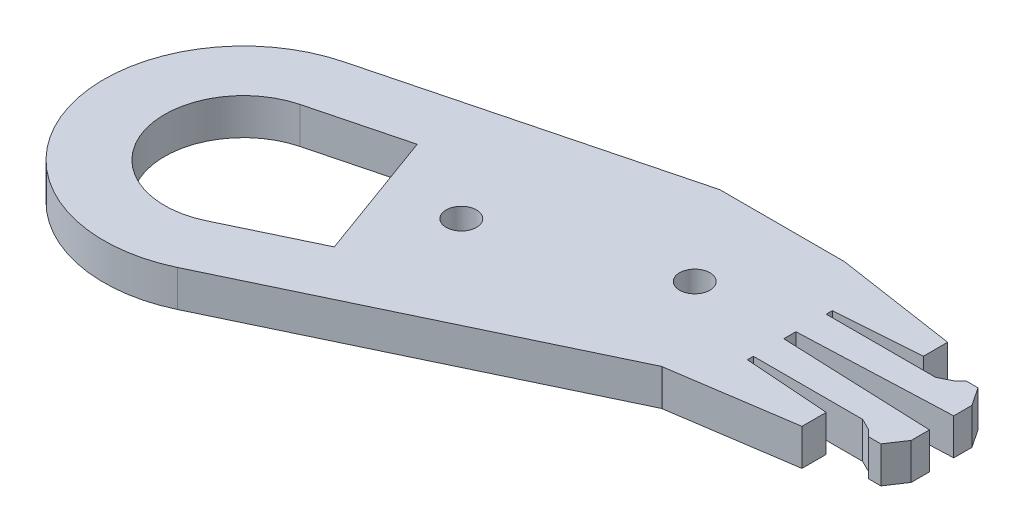
from build123d import *

# Parameters (mm, degrees)
SKETCH4_R           = 1.25
BOSS_EXTRUDE2_DEPTH = 3


with BuildPart() as part:
    # Sketch4 → Boss-Extrude2 (new body)
    with BuildSketch(Plane(origin=(0, 0, 0), x_dir=(1, 0, 0), z_dir=(0, 1, 0))):
        with BuildLine():
            Line((-2.879370047, 11.133697864), (21.737293787, 17.5))
            Line((21.737293787, 17.5), (32, 17.5))
            Line((32, 17.5), (42, 16))
            Line((42, 16), (42, 14))
            Line((42, 14), (35, 13.5))
            Line((35, 13.5), (35, 13))
            Line((35, 13), (44, 13))
            Line((44, 13), (45, 13.5))
            Line((45, 13.5), (45.5, 14))
            Line((45.5, 14), (46.5, 14))
            Line((46.5, 14), (47.5, 12.5))
            Line((47.5, 12.5), (47.5, 11))
            Line((47.5, 11), (35, 10.5))
            Line((35, 10.5), (35, 9.5))
            Line((35, 9.5), (47.5, 9))
            Line((47.5, 9), (47.5, 7.5))
            Line((47.5, 7.5), (46.5, 6))
            Line((46.5, 6), (45.5, 6))
            Line((45.5, 6), (45, 6.5))
            Line((45, 6.5), (44, 7))
            Line((44, 7), (35, 7))
            Line((35, 7), (35, 6.5))
            Line((35, 6.5), (42, 6))
            Line((42, 6), (42, 4))
            Line((42, 4), (32, 2.5))
            Line((32, 2.5), (31.953794717, 2.5))
            Line((31.953794717, 2.5), (4.950877613, -10.37973077))
            ThreePointArc((4.950877613, -10.37973077), (-10.806465139, -3.933231648), (-2.879370047, 11.133697864))
        make_face()
        with Locations((13.155696691, 4.788282007)):
            Circle(SKETCH4_R, mode=Mode.SUBTRACT)
        with Locations((27.251086003, 9.918584156)):
            Circle(SKETCH4_R, mode=Mode.SUBTRACT)
        with BuildLine():
            Line((6.033902904, 8.274325422), (9.94087165, -2.459982986))
            Line((9.94087165, -2.459982986), (2.798322129, -5.866804348))
            ThreePointArc((2.798322129, -5.866804348), (-6.108002035, -2.223130932), (-1.627470026, 6.292959662))
            Line((-1.627470026, 6.292959662), (6.033902904, 8.274325422))
        make_face(mode=Mode.SUBTRACT)
    extrude(amount=-BOSS_EXTRUDE2_DEPTH)


solid = part.part
